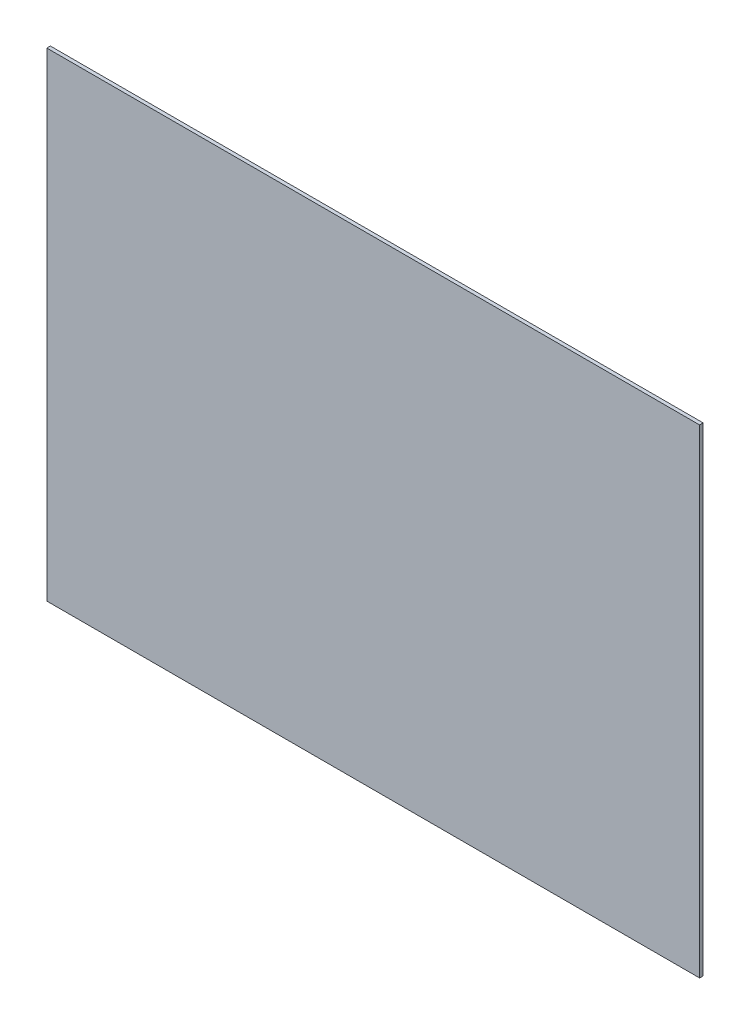
from build123d import *

# Parameters (mm, degrees)
SKETCH1_W           = 584.2
SKETCH1_H           = 428.625
BOSS_EXTRUDE1_DEPTH = 3.175


with BuildPart() as part:
    # Sketch1 → Boss-Extrude1 (new body)
    with BuildSketch(Plane.XY):
        with Locations((292.1, 214.3125)):
            Rectangle(SKETCH1_W, SKETCH1_H)
    extrude(amount=BOSS_EXTRUDE1_DEPTH)


solid = part.part
